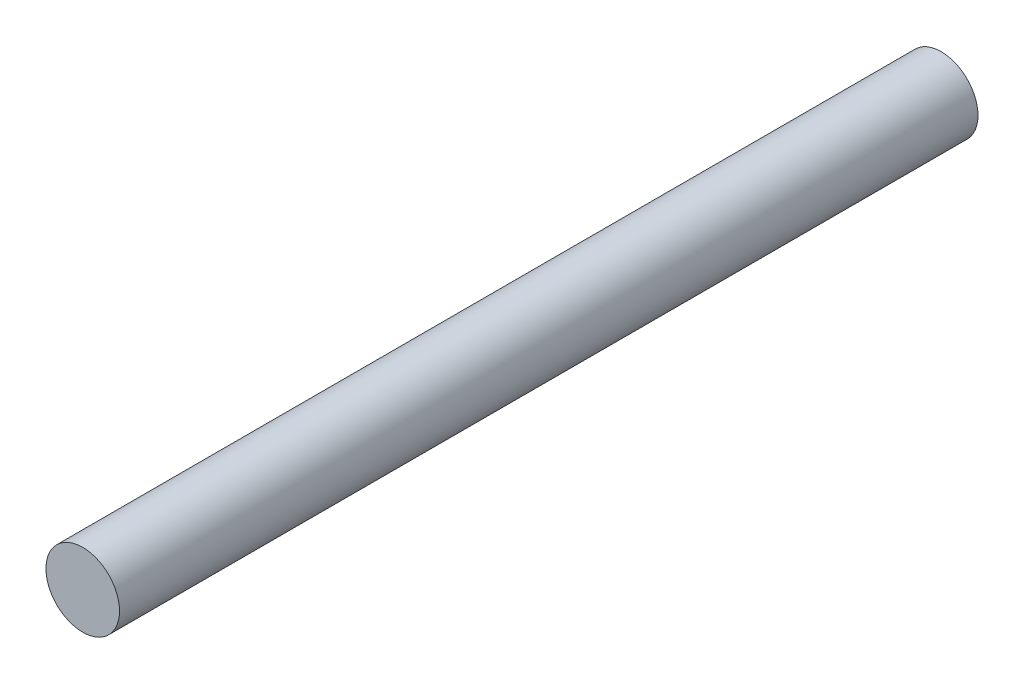
from build123d import *

# Parameters (mm, degrees)
SKETCH2_R           = 1.5
BOSS_EXTRUDE1_DEPTH = 35


with BuildPart() as part:
    # Sketch2 → Boss-Extrude1 (new body)
    with BuildSketch(Plane.XY):
        Circle(SKETCH2_R)
    extrude(amount=BOSS_EXTRUDE1_DEPTH)


solid = part.part
